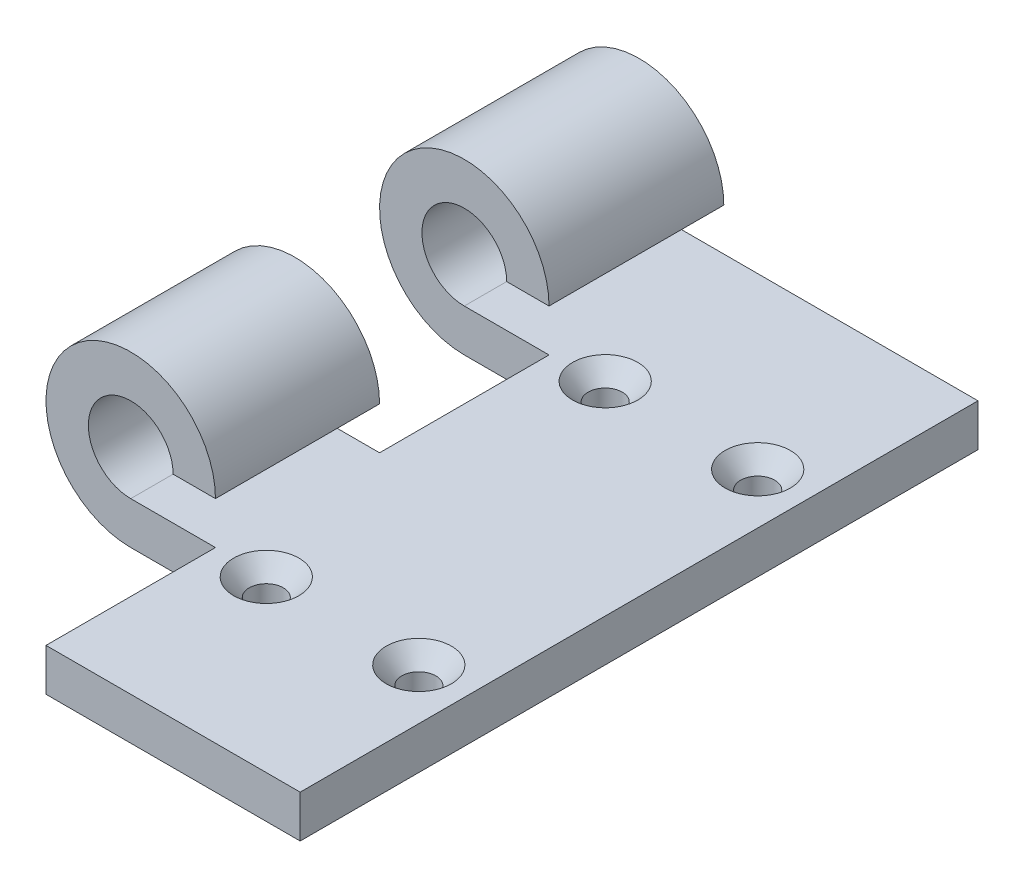
from build123d import *

# Parameters (mm, degrees)
EXTRUDE_THIN1_DEPTH                             = 50.8
CUT_EXTRUDE2_START                              = -7.35
SKETCH3_W                                       = 25.4
SKETCH3_H                                       = 25.4
CUT_EXTRUDE2_DEPTH                              = 27.4
LPATTERN1_COUNT                                 = 2
LPATTERN1_PITCH                                 = 50
CSK_FOR_10_FLAT_HEAD_MACHINE_SCREW1_D           = 5.1054
CSK_FOR_10_FLAT_HEAD_MACHINE_SCREW1_CSINK_D     = 9.779
CSK_FOR_10_FLAT_HEAD_MACHINE_SCREW1_CSINK_ANGLE = 82
LPATTERN2_COUNT                                 = 2
LPATTERN2_PITCH                                 = 50.8
LPATTERN2_COUNT_DIR2                            = 2
LPATTERN2_PITCH_DIR2                            = 22.86


with BuildPart() as part:
    # Sketch1 → Extrude-Thin1 (new body, symmetric)
    with BuildSketch(Plane.XY):
        with BuildLine():
            Line((0, 0), (-50.8, 0))
            ThreePointArc((-50.8, 0), (-59.780256121, 21.680256121), (-38.1, 12.7))
            Line((-38.1, 12.7), (-44.45, 12.7))
            ThreePointArc((-44.45, 12.7), (-55.290128061, 17.190128061), (-50.8, 6.35))
            Line((-50.8, 6.35), (0, 6.35))
            Line((0, 6.35), (0, 0))
        make_face()
    extrude(amount=EXTRUDE_THIN1_DEPTH, both=True)

    # Sketch3 → Cut-Extrude2 (cut)
    with BuildSketch(Plane(origin=(0, 6.35, 0), x_dir=(1, 0, 0), z_dir=(0, 1, 0)).offset(CUT_EXTRUDE2_START)):
        with Locations((-50.8, -38.1)):
            Rectangle(SKETCH3_W, SKETCH3_H)
    cut_extrude2 = extrude(amount=CUT_EXTRUDE2_DEPTH, mode=Mode.SUBTRACT)

    # LPattern1: Cut-Extrude2 ×2
    with Locations(*[(0, 0, -i * LPATTERN1_PITCH) for i in range(1, LPATTERN1_COUNT)]):
        add(cut_extrude2, mode=Mode.SUBTRACT)

    # CSK for #10 Flat Head Machine Screw1 (through all)
    with Locations(Plane(origin=(0, 6.35, 0), x_dir=(1, 0, 0), z_dir=(0, 1, 0))):
        with Locations((-30.48, 25.4)):
            csk_for_10_flat_head_machine_screw1 = CounterSinkHole(CSK_FOR_10_FLAT_HEAD_MACHINE_SCREW1_D / 2, CSK_FOR_10_FLAT_HEAD_MACHINE_SCREW1_CSINK_D / 2, counter_sink_angle=CSK_FOR_10_FLAT_HEAD_MACHINE_SCREW1_CSINK_ANGLE)

    # LPattern2: CSK for _10 Flat Head Machine Screw1 2 × 2
    with Locations(*[(j * LPATTERN2_PITCH_DIR2, 0, i * LPATTERN2_PITCH) for i in range(LPATTERN2_COUNT) for j in range(LPATTERN2_COUNT_DIR2) if (i, j) != (0, 0)]):
        add(csk_for_10_flat_head_machine_screw1, mode=Mode.SUBTRACT)


solid = part.part
